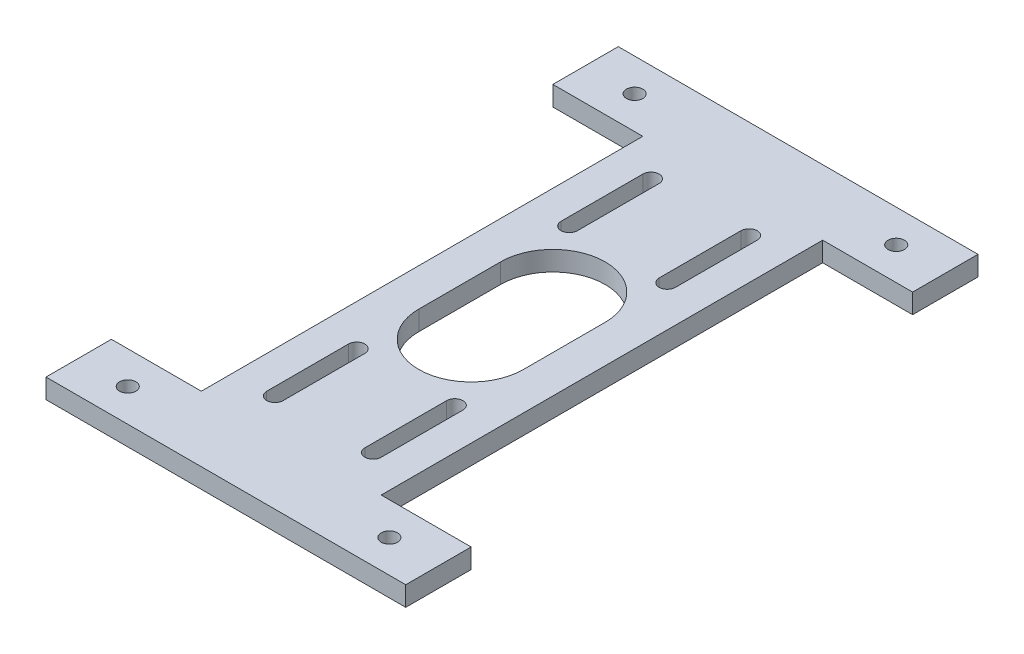
from build123d import *

# Parameters (mm, degrees)
SKETCH1_W           = 55
SKETCH1_H           = 135
SKETCH1_W_2         = 110
SKETCH1_H_2         = 20
SKETCH1_R           = 2.5
BOSS_EXTRUDE1_DEPTH = 6


with BuildPart() as part:
    # Sketch1 → Boss-Extrude1 (new body)
    with BuildSketch(Plane(origin=(0, 0, 0), x_dir=(1, 0, 0), z_dir=(0, 1, 0))):
        Rectangle(SKETCH1_W, SKETCH1_H)
        with BuildLine():
            Line((-16, -12.5), (-16, 12.5))
            ThreePointArc((-16, 12.5), (0, 28.5), (16, 12.5))
            Line((16, 12.5), (16, -12.5))
            ThreePointArc((16, -12.5), (0, -28.5), (-16, -12.5))
        make_face(mode=Mode.SUBTRACT)
        with BuildLine():
            Line((-12.5, -32.5), (-12.5, -57.5))
            ThreePointArc((-12.5, -57.5), (-15, -60), (-17.5, -57.5))
            Line((-17.5, -57.5), (-17.5, -32.5))
            ThreePointArc((-17.5, -32.5), (-15, -30), (-12.5, -32.5))
        make_face(mode=Mode.SUBTRACT)
        with BuildLine():
            Line((-12.5, 32.5), (-12.5, 57.5))
            ThreePointArc((-12.5, 57.5), (-15, 60), (-17.5, 57.5))
            Line((-17.5, 57.5), (-17.5, 32.5))
            ThreePointArc((-17.5, 32.5), (-15, 30), (-12.5, 32.5))
        make_face(mode=Mode.SUBTRACT)
        with BuildLine():
            Line((12.5, -32.5), (12.5, -57.5))
            ThreePointArc((12.5, -57.5), (15, -60), (17.5, -57.5))
            Line((17.5, -57.5), (17.5, -32.5))
            ThreePointArc((17.5, -32.5), (15, -30), (12.5, -32.5))
        make_face(mode=Mode.SUBTRACT)
        with BuildLine():
            Line((12.5, 32.5), (12.5, 57.5))
            ThreePointArc((12.5, 57.5), (15, 60), (17.5, 57.5))
            Line((17.5, 57.5), (17.5, 32.5))
            ThreePointArc((17.5, 32.5), (15, 30), (12.5, 32.5))
        make_face(mode=Mode.SUBTRACT)
        with Locations((0, -77.5)):
            Rectangle(SKETCH1_W_2, SKETCH1_H_2)
        with Locations((-40, -77.5)):
            Circle(SKETCH1_R, mode=Mode.SUBTRACT)
        with Locations((40, -77.5)):
            Circle(SKETCH1_R, mode=Mode.SUBTRACT)
        with Locations((0, 77.5)):
            Rectangle(SKETCH1_W_2, SKETCH1_H_2)
        with Locations((40, 77.5)):
            Circle(SKETCH1_R, mode=Mode.SUBTRACT)
        with Locations((-40, 77.5)):
            Circle(SKETCH1_R, mode=Mode.SUBTRACT)
    extrude(amount=BOSS_EXTRUDE1_DEPTH)


solid = part.part
